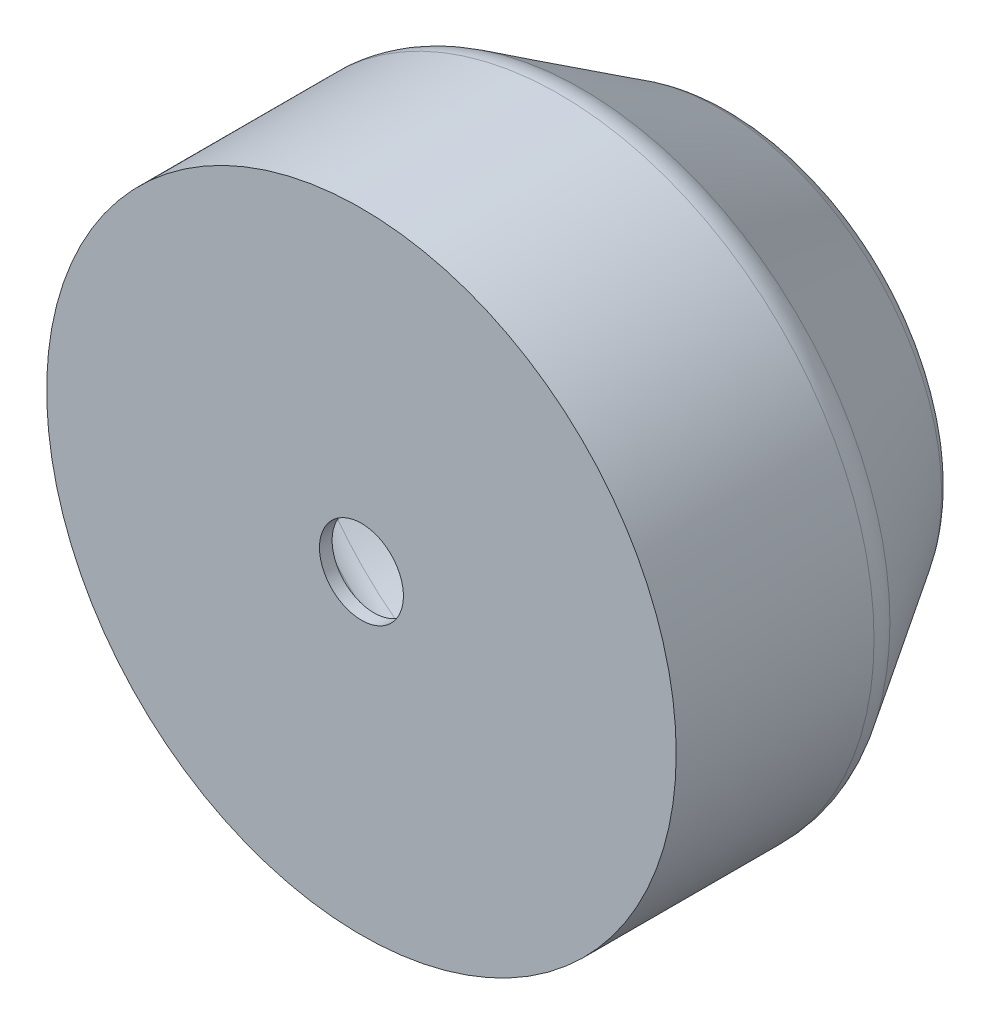
from build123d import *

# Parameters (mm, degrees)
SKETCH_1_R          = 75
EXTRUDE_1_DEPTH     = 50
SKETCH_3_R          = 50
SKETCH_2_R          = 75
FILLET_1_R          = 10
SKETCH_4_R          = 10
CUT_EXTRUDE_1_DEPTH = 140.104278635
SHELL_1_T           = -3


with BuildPart() as part:
    # 草图1 → 凸台-拉伸1 (new body)
    with BuildSketch(Plane.XY):
        Circle(SKETCH_1_R)
    extrude(amount=EXTRUDE_1_DEPTH)

    # 草图3 → 放样1 section 0
    with BuildSketch(Plane(origin=(0, 0, -40), x_dir=(-1, 0, 0), z_dir=(0, 0, -1))):
        Circle(SKETCH_3_R)
    # 草图2 → 放样1 section 1
    with BuildSketch(Plane(origin=(0, 0, 0), x_dir=(-1, 0, 0), z_dir=(0, 0, -1))):
        Circle(SKETCH_2_R)
    loft()

    # 圆角1
    fillet_1_edges = [part.edges().sort_by_distance(p)[0] for p in [
        (50, 0, -40),
        (0, 75, 0),
    ]]
    fillet(fillet_1_edges, radius=FILLET_1_R)

    # 草图4 → 切除-拉伸1 (cut, through all)
    with BuildSketch(Plane(origin=(0, 0, -40), x_dir=(-1, 0, 0), z_dir=(0, 0, -1))):
        Circle(SKETCH_4_R)
    extrude(amount=-CUT_EXTRUDE_1_DEPTH, mode=Mode.SUBTRACT)

    # 抽壳1
    shell_1_openings = [part.faces().sort_by_distance(p)[0] for p in [
        (10, 0, 5),
    ]]
    offset(amount=SHELL_1_T, openings=shell_1_openings, kind=Kind.INTERSECTION)


solid = part.part
